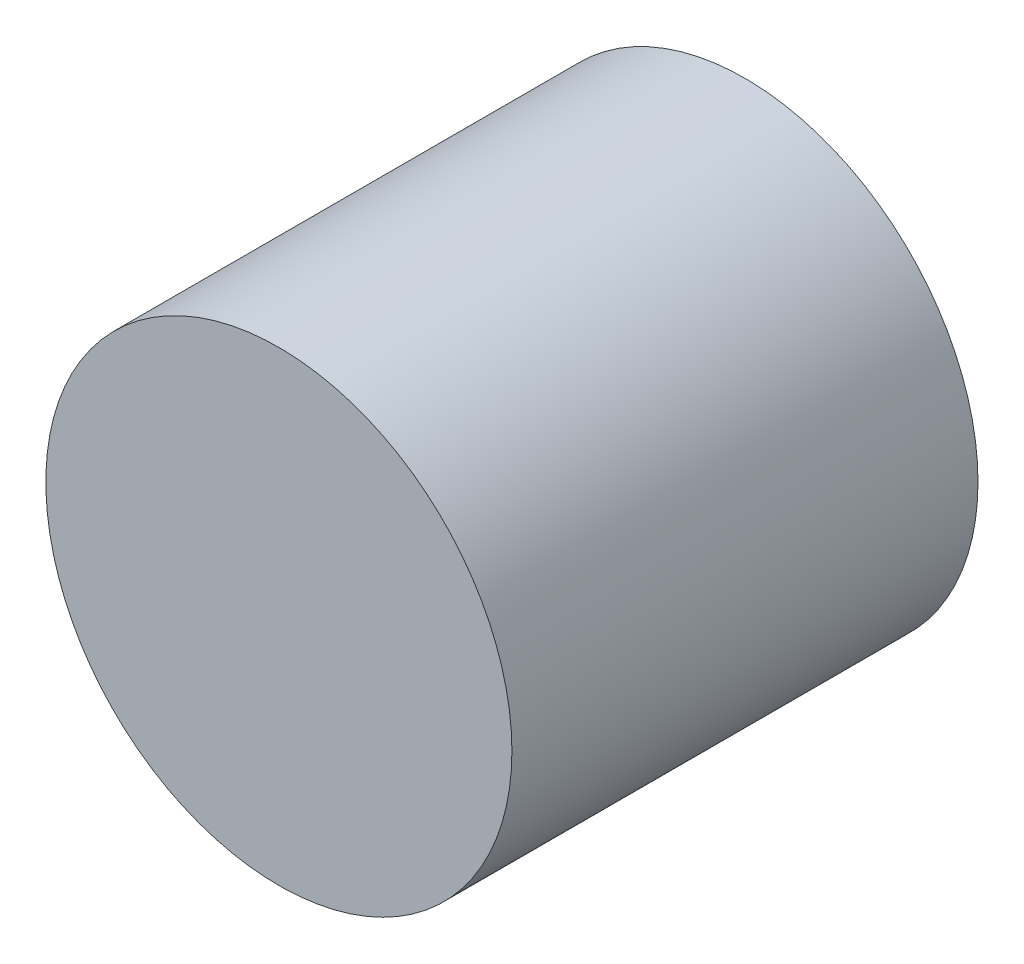
from build123d import *

# Parameters (mm, degrees)
SKETCH_1_R      = 5
EXTRUDE_1_DEPTH = 10


with BuildPart() as part:
    # 草图1 → 凸台-拉伸1 (new body)
    with BuildSketch(Plane.XY):
        Circle(SKETCH_1_R)
    extrude(amount=EXTRUDE_1_DEPTH)


solid = part.part
